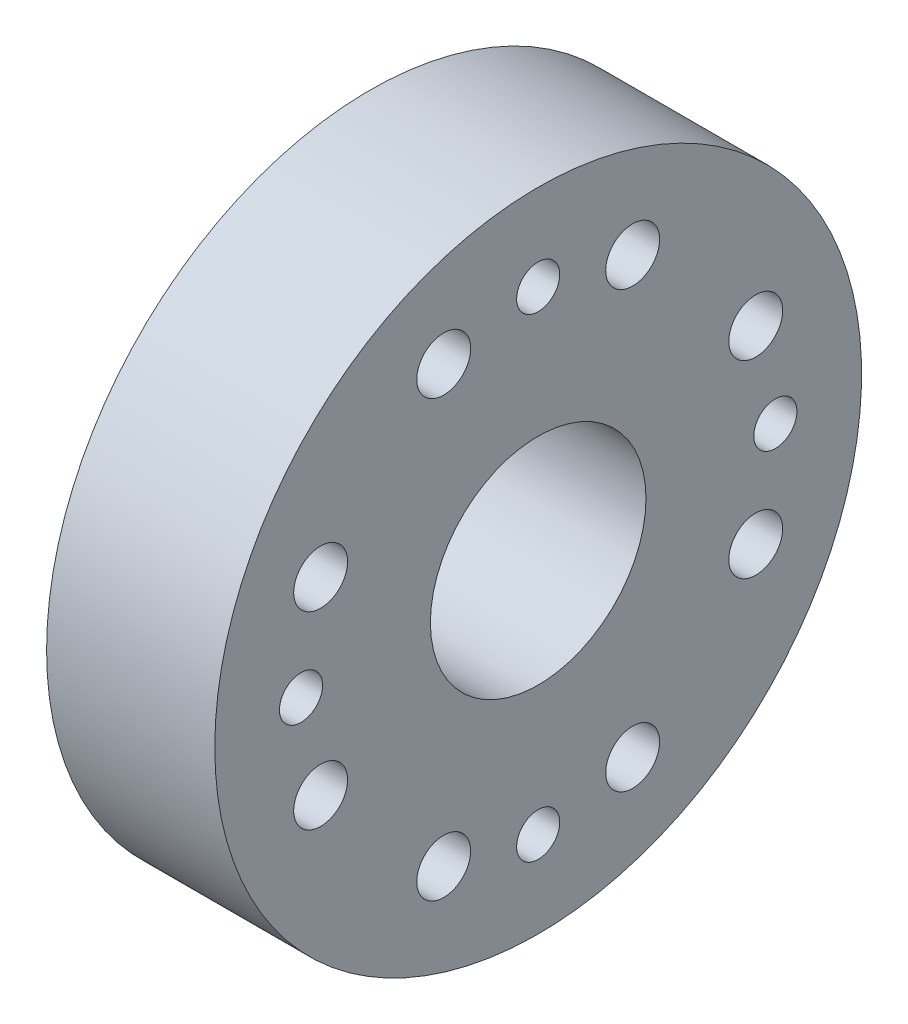
from build123d import *

# Parameters (mm, degrees)
SKETCH4_R          = 1
SKETCH4_R_2        = 1.25
EXTRUDE2_DEPTH     = 8.8
SKETCH5_R          = 5
CUT_EXTRUDE1_DEPTH = 8.8


with BuildPart() as part:
    # Sketch1 → Revolve1 (revolve)
    with BuildSketch(Plane.XY):
        Polygon((6.609375, 15), (1.190625, 15), (0, 15), (0, 14), (0, 0), (7.8, 0), (7.8, 14), (7.8, 15), align=None)
    revolve(axis=Axis((0, 0, 0), (1, 0, 0)))

    # Sketch4 → Extrude2 (cut, through all)
    with BuildSketch(Plane(origin=(7.8, 0, 0), x_dir=(0, 0, -1), z_dir=(1, 0, 0))):
        with Locations((0, 11)):
            Circle(SKETCH4_R)
        with Locations((-4.381841494, 10.089572098)):
            Circle(SKETCH4_R_2)
        with Locations((4.381841494, 10.089572098)):
            Circle(SKETCH4_R_2)
        with Locations((10.089572098, -4.381841494)):
            Circle(SKETCH4_R_2)
        with Locations((11, 0)):
            Circle(SKETCH4_R)
        with Locations((10.089572098, 4.381841494)):
            Circle(SKETCH4_R_2)
        with Locations((-4.381841494, -10.089572098)):
            Circle(SKETCH4_R_2)
        with Locations((0, -11)):
            Circle(SKETCH4_R)
        with Locations((4.381841494, -10.089572098)):
            Circle(SKETCH4_R_2)
        with Locations((-10.089572098, 4.381841494)):
            Circle(SKETCH4_R_2)
        with Locations((-11, 0)):
            Circle(SKETCH4_R)
        with Locations((-10.089572098, -4.381841494)):
            Circle(SKETCH4_R_2)
    extrude(amount=-EXTRUDE2_DEPTH, mode=Mode.SUBTRACT)

    # Sketch5 → Cut-Extrude1 (cut, through all)
    with BuildSketch(Plane(origin=(7.8, 0, 0), x_dir=(0, 0, -1), z_dir=(1, 0, 0))):
        Circle(SKETCH5_R)
    extrude(amount=-CUT_EXTRUDE1_DEPTH, mode=Mode.SUBTRACT)


solid = part.part
